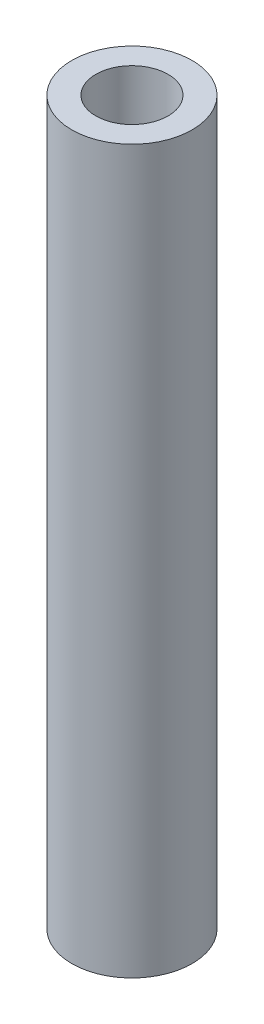
from build123d import *

# Parameters (mm, degrees)
SKETCH1_R           = 2.5
SKETCH1_R_2         = 1.5
BOSS_EXTRUDE1_DEPTH = 30


with BuildPart() as part:
    # Sketch1 → Boss-Extrude1 (new body)
    with BuildSketch(Plane(origin=(0, 0, 0), x_dir=(1, 0, 0), z_dir=(0, 1, 0))):
        Circle(SKETCH1_R)
        Circle(SKETCH1_R_2, mode=Mode.SUBTRACT)
    extrude(amount=BOSS_EXTRUDE1_DEPTH)


solid = part.part
